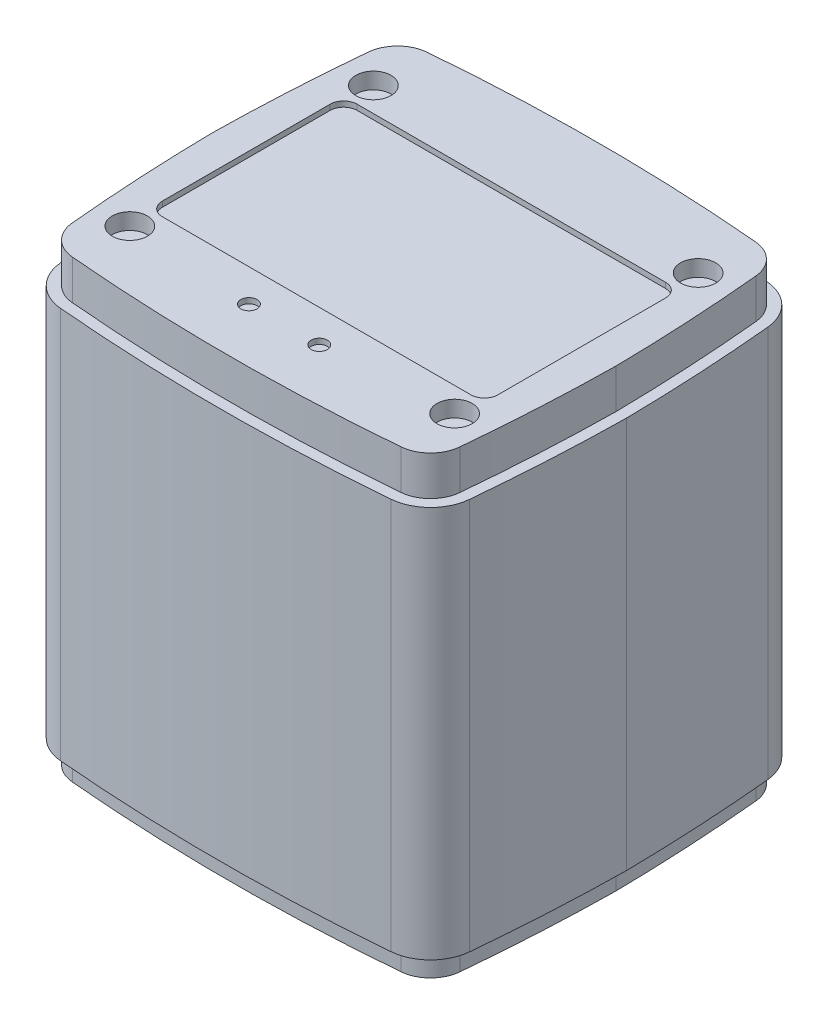
from build123d import *

# Parameters (mm, degrees)
BOSS_EXTRUDE1_DEPTH = 72.4
BOSS_EXTRUDE2_DEPTH = 7.3
BOSS_EXTRUDE3_DEPTH = 4.3
SKETCH4_R           = 25
BOSS_EXTRUDE4_DEPTH = 6.5
SKETCH5_R           = 3.25
CUT_EXTRUDE1_DEPTH  = 3
CUT_EXTRUDE2_DEPTH  = 1
SKETCH7_R           = 1.5
CUT_EXTRUDE3_DEPTH  = 1
SKETCH8_R           = 20
CUT_EXTRUDE4_DEPTH  = 10


with BuildPart() as part:
    # Sketch1 → Boss-Extrude1 (new body)
    with BuildSketch(Plane(origin=(0, 0, 0), x_dir=(1, 0, 0), z_dir=(0, 1, 0))):
        with BuildLine():
            ThreePointArc((69.840771002, 70.864970002), (39.3, 72.2), (8.759228998, 70.864970002))
            ThreePointArc((8.759228998, 70.864970002), (3.821292476, 68.573105669), (1.493169033, 63.652160592))
            ThreePointArc((1.493169033, 63.652160592), (0.466996736, 49.89123235), (0, 36.1))
            ThreePointArc((0, 36.1), (0.466996736, 22.30876765), (1.493169033, 8.547839408))
            ThreePointArc((1.493169033, 8.547839408), (3.821292476, 3.626894331), (8.759228998, 1.335029998))
            ThreePointArc((8.759228998, 1.335029998), (39.3, 0), (69.840771002, 1.335029998))
            ThreePointArc((69.840771002, 1.335029998), (74.778707524, 3.626894331), (77.106830967, 8.547839408))
            ThreePointArc((77.106830967, 8.547839408), (78.133003264, 22.30876765), (78.6, 36.1))
            ThreePointArc((78.6, 36.1), (78.133003264, 49.89123235), (77.106830967, 63.652160592))
            ThreePointArc((77.106830967, 63.652160592), (74.778707524, 68.573105669), (69.840771002, 70.864970002))
        make_face()
    extrude(amount=BOSS_EXTRUDE1_DEPTH)

    # Sketch2 → Boss-Extrude2 (add)
    with BuildSketch(Plane(origin=(0, 72.4, 0), x_dir=(1, 0, 0), z_dir=(0, 1, 0))):
        with BuildLine():
            ThreePointArc((69.66625231, 68.872598745), (39.3, 70.2), (8.93374769, 68.872598745))
            ThreePointArc((8.93374769, 68.872598745), (5.230295298, 67.153700495), (3.484202716, 63.462991687))
            ThreePointArc((3.484202716, 63.462991687), (2.464800099, 49.796540149), (2.000184882, 36.1))
            ThreePointArc((2.000184882, 36.1), (2.464800099, 22.403459851), (3.484202716, 8.737008313))
            ThreePointArc((3.484202716, 8.737008313), (5.230295298, 5.046299505), (8.93374769, 3.327401255))
            ThreePointArc((8.93374769, 3.327401255), (39.3, 2), (69.66625231, 3.327401255))
            ThreePointArc((69.66625231, 3.327401255), (73.369704702, 5.046299505), (75.115797284, 8.737008313))
            ThreePointArc((75.115797284, 8.737008313), (76.135199901, 22.403459851), (76.599815118, 36.1))
            ThreePointArc((76.599815118, 36.1), (76.135199901, 49.796540149), (75.115797284, 63.462991687))
            ThreePointArc((75.115797284, 63.462991687), (73.369704702, 67.153700495), (69.66625231, 68.872598745))
        make_face()
    extrude(amount=BOSS_EXTRUDE2_DEPTH)

    # Sketch3 → Boss-Extrude3 (add)
    with BuildSketch(Plane.XZ):
        with BuildLine():
            ThreePointArc((69.66625231, -3.327401255), (39.3, -2), (8.93374769, -3.327401255))
            ThreePointArc((8.93374769, -3.327401255), (5.230295298, -5.046299505), (3.484202716, -8.737008313))
            ThreePointArc((3.484202716, -8.737008313), (2.464800099, -22.403459851), (2.000184882, -36.1))
            ThreePointArc((2.000184882, -36.1), (2.464800099, -49.796540149), (3.484202716, -63.462991687))
            ThreePointArc((3.484202716, -63.462991687), (5.230295298, -67.153700495), (8.93374769, -68.872598745))
            ThreePointArc((8.93374769, -68.872598745), (39.3, -70.2), (69.66625231, -68.872598745))
            ThreePointArc((69.66625231, -68.872598745), (73.369704702, -67.153700495), (75.115797284, -63.462991687))
            ThreePointArc((75.115797284, -63.462991687), (76.135199901, -49.796540149), (76.599815118, -36.1))
            ThreePointArc((76.599815118, -36.1), (76.135199901, -22.403459851), (75.115797284, -8.737008313))
            ThreePointArc((75.115797284, -8.737008313), (73.369704702, -5.046299505), (69.66625231, -3.327401255))
        make_face()
    extrude(amount=BOSS_EXTRUDE3_DEPTH)

    # Sketch4 → Boss-Extrude4 (add)
    with BuildSketch(Plane.XZ.offset(4.3)):
        with Locations((39.3, -36.1)):
            Circle(SKETCH4_R)
    extrude(amount=BOSS_EXTRUDE4_DEPTH)

    # Sketch5 → Cut-Extrude1 (cut)
    with BuildSketch(Plane(origin=(0, 79.7, 0), x_dir=(1, 0, 0), z_dir=(0, 1, 0))):
        with Locations((69.3, 58.6)):
            Circle(SKETCH5_R)
        with Locations((69.3, 13.6)):
            Circle(SKETCH5_R)
        with Locations((9.3, 13.6)):
            Circle(SKETCH5_R)
        with Locations((9.3, 58.6)):
            Circle(SKETCH5_R)
    extrude(amount=-CUT_EXTRUDE1_DEPTH, mode=Mode.SUBTRACT)

    # Sketch6 → Cut-Extrude2 (cut)
    with BuildSketch(Plane(origin=(0, 79.7, 0), x_dir=(1, 0, 0), z_dir=(0, 1, 0))):
        with BuildLine():
            Line((10.8, 54.1), (67.8, 54.1))
            ThreePointArc((67.8, 54.1), (69.567766953, 53.367766953), (70.3, 51.6))
            Line((70.3, 51.6), (70.3, 20.6))
            ThreePointArc((70.3, 20.6), (69.567766953, 18.832233047), (67.8, 18.1))
            Line((67.8, 18.1), (10.8, 18.1))
            ThreePointArc((10.8, 18.1), (9.032233047, 18.832233047), (8.3, 20.6))
            Line((8.3, 20.6), (8.3, 51.6))
            ThreePointArc((8.3, 51.6), (9.032233047, 53.367766953), (10.8, 54.1))
        make_face()
    extrude(amount=-CUT_EXTRUDE2_DEPTH, mode=Mode.SUBTRACT)

    # Sketch7 → Cut-Extrude3 (cut)
    with BuildSketch(Plane(origin=(0, 79.7, 0), x_dir=(1, 0, 0), z_dir=(0, 1, 0))):
        with Locations((32.8, 12.1)):
            Circle(SKETCH7_R)
        with Locations((45.8, 12.1)):
            Circle(SKETCH7_R)
    extrude(amount=-CUT_EXTRUDE3_DEPTH, mode=Mode.SUBTRACT)

    # Sketch8 → Cut-Extrude4 (cut)
    with BuildSketch(Plane.XZ.offset(10.8)):
        with Locations((39.3, -36.1)):
            Circle(SKETCH8_R)
    extrude(amount=-CUT_EXTRUDE4_DEPTH, mode=Mode.SUBTRACT)


solid = part.part
